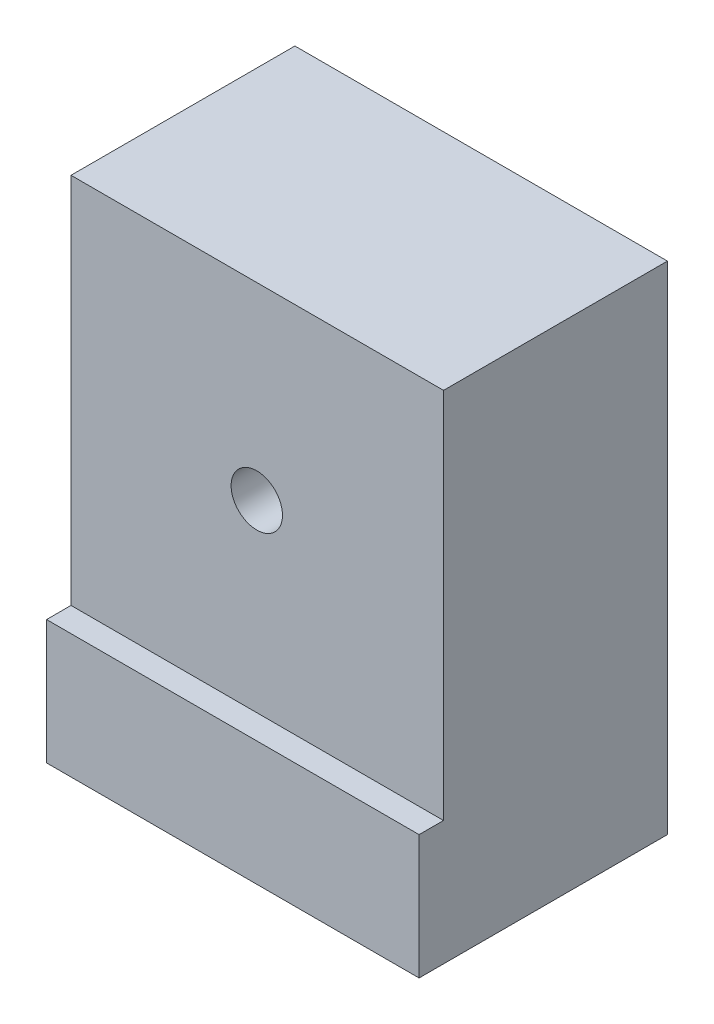
from build123d import *

# Parameters (mm, degrees)
SKETCH1_W           = 76.2
SKETCH1_H           = 50.8
BOSS_EXTRUDE1_DEPTH = 101.6
SKETCH2_R           = 5.25
CUT_EXTRUDE1_DEPTH  = 300
SKETCH3_W           = 76.2
SKETCH3_H           = 76.2
CUT_EXTRUDE2_DEPTH  = 5


with BuildPart() as part:
    # Sketch1 → Boss-Extrude1 (new body)
    with BuildSketch(Plane(origin=(0, 0, 0), x_dir=(1, 0, 0), z_dir=(0, 1, 0))):
        with Locations((38.1, 25.4)):
            Rectangle(SKETCH1_W, SKETCH1_H)
    extrude(amount=BOSS_EXTRUDE1_DEPTH)

    # Sketch2 → Cut-Extrude1 (cut)
    with BuildSketch(Plane.XY):
        with Locations((38, 63)):
            Circle(SKETCH2_R)
    extrude(amount=-CUT_EXTRUDE1_DEPTH, mode=Mode.SUBTRACT)

    # Sketch3 → Cut-Extrude2 (cut)
    with BuildSketch(Plane.XY):
        with Locations((38.1, 63.5)):
            Rectangle(SKETCH3_W, SKETCH3_H)
    extrude(amount=-CUT_EXTRUDE2_DEPTH, mode=Mode.SUBTRACT)


solid = part.part
